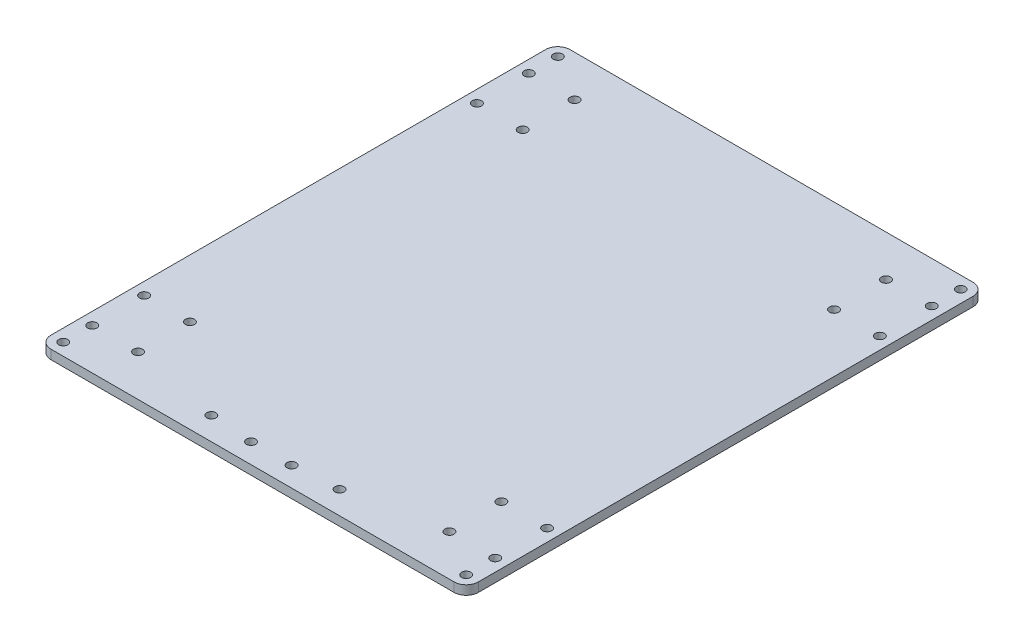
from build123d import *

# Parameters (mm, degrees)
SKETCH1_R           = 1.5
BOSS_EXTRUDE1_DEPTH = 3


with BuildPart() as part:
    # Sketch1 → Boss-Extrude1 (new body)
    with BuildSketch(Plane(origin=(0, 0, 0), x_dir=(1, 0, 0), z_dir=(0, 1, 0))):
        with BuildLine():
            Line((-4, 0), (-136, 0))
            ThreePointArc((-136, 0), (-138.828427125, 1.171572875), (-140, 4))
            Line((-140, 4), (-140, 166))
            ThreePointArc((-140, 166), (-138.828427125, 168.828427125), (-136, 170))
            Line((-136, 170), (-4, 170))
            ThreePointArc((-4, 170), (-1.171572875, 168.828427125), (0, 166))
            Line((0, 166), (0, 4))
            ThreePointArc((0, 4), (-1.171572875, 1.171572875), (-4, 0))
        make_face()
        with Locations((-136, 166)):
            Circle(SKETCH1_R, mode=Mode.SUBTRACT)
        with Locations((-4, 166)):
            Circle(SKETCH1_R, mode=Mode.SUBTRACT)
        with Locations((-136, 4)):
            Circle(SKETCH1_R, mode=Mode.SUBTRACT)
        with Locations((-4, 4)):
            Circle(SKETCH1_R, mode=Mode.SUBTRACT)
        with Locations((-121, 156.5)):
            Circle(SKETCH1_R, mode=Mode.SUBTRACT)
        with Locations((-136, 156.5)):
            Circle(SKETCH1_R, mode=Mode.SUBTRACT)
        with Locations((-136, 139.5)):
            Circle(SKETCH1_R, mode=Mode.SUBTRACT)
        with Locations((-121, 139.5)):
            Circle(SKETCH1_R, mode=Mode.SUBTRACT)
        with Locations((-19, 156.5)):
            Circle(SKETCH1_R, mode=Mode.SUBTRACT)
        with Locations((-4, 156.5)):
            Circle(SKETCH1_R, mode=Mode.SUBTRACT)
        with Locations((-4, 139.5)):
            Circle(SKETCH1_R, mode=Mode.SUBTRACT)
        with Locations((-19, 139.5)):
            Circle(SKETCH1_R, mode=Mode.SUBTRACT)
        with Locations((-63.690651325, 6.5)):
            Circle(SKETCH1_R, mode=Mode.SUBTRACT)
        with Locations((-77, 6.5)):
            Circle(SKETCH1_R, mode=Mode.SUBTRACT)
        with Locations((-121, 30.5)):
            Circle(SKETCH1_R, mode=Mode.SUBTRACT)
        with Locations((-136, 30.5)):
            Circle(SKETCH1_R, mode=Mode.SUBTRACT)
        with Locations((-136, 13.5)):
            Circle(SKETCH1_R, mode=Mode.SUBTRACT)
        with Locations((-121, 13.5)):
            Circle(SKETCH1_R, mode=Mode.SUBTRACT)
        with Locations((-19, 30.5)):
            Circle(SKETCH1_R, mode=Mode.SUBTRACT)
        with Locations((-4, 30.5)):
            Circle(SKETCH1_R, mode=Mode.SUBTRACT)
        with Locations((-19, 13.5)):
            Circle(SKETCH1_R, mode=Mode.SUBTRACT)
        with Locations((-4, 13.5)):
            Circle(SKETCH1_R, mode=Mode.SUBTRACT)
        with Locations((-91, 7.5)):
            Circle(SKETCH1_R, mode=Mode.SUBTRACT)
        with Locations((-49, 7.5)):
            Circle(SKETCH1_R, mode=Mode.SUBTRACT)
    extrude(amount=BOSS_EXTRUDE1_DEPTH)


solid = part.part
